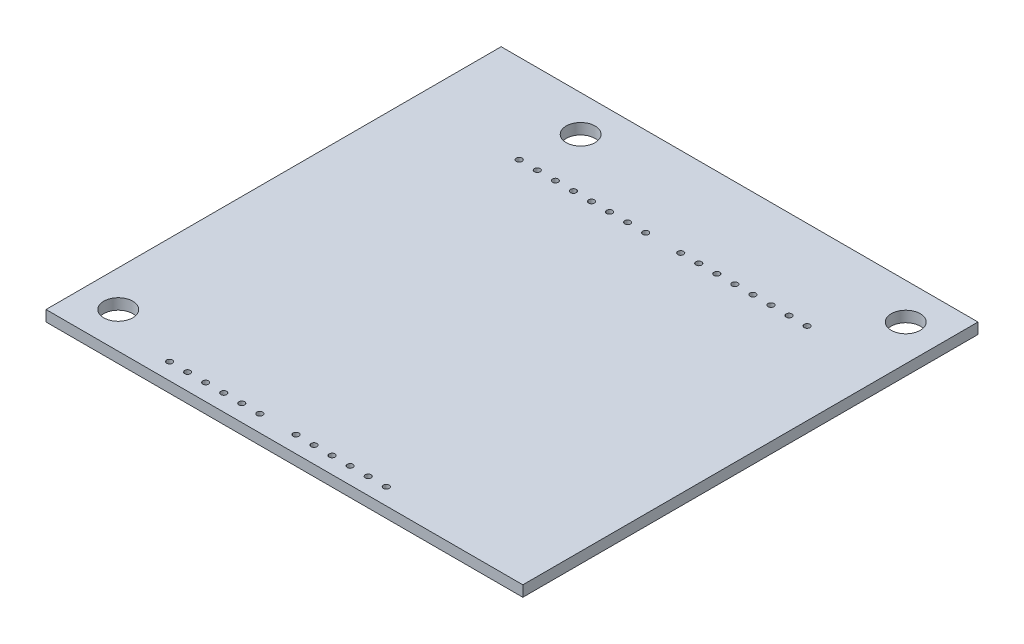
from build123d import *

# Parameters (mm, degrees)
SKETCH1_R           = 0.4
SKETCH1_R_2         = 2
BOSS_EXTRUDE1_DEPTH = 1.5


with BuildPart() as part:
    # Sketch1 → Boss-Extrude1 (new body)
    with BuildSketch(Plane(origin=(0, 0, 0), x_dir=(1, 0, 0), z_dir=(0, 1, 0))):
        Polygon((-28, -26.5), (28, -26.5), (28, 26.5), (28, 36.5), (-38, 36.5), (-38, -26.5), align=None)
        with Locations((-23.2, 24.2)):
            Circle(SKETCH1_R, mode=Mode.SUBTRACT)
        with Locations((-20.7, 24.2)):
            Circle(SKETCH1_R, mode=Mode.SUBTRACT)
        with Locations((-18.2, 24.2)):
            Circle(SKETCH1_R, mode=Mode.SUBTRACT)
        with Locations((-15.7, 24.2)):
            Circle(SKETCH1_R, mode=Mode.SUBTRACT)
        with Locations((-13.2, 24.2)):
            Circle(SKETCH1_R, mode=Mode.SUBTRACT)
        with Locations((-10.7, 24.2)):
            Circle(SKETCH1_R, mode=Mode.SUBTRACT)
        with Locations((-8.2, 24.2)):
            Circle(SKETCH1_R, mode=Mode.SUBTRACT)
        with Locations((-5.7, 24.2)):
            Circle(SKETCH1_R, mode=Mode.SUBTRACT)
        with Locations((-10.7, -24.2)):
            Circle(SKETCH1_R, mode=Mode.SUBTRACT)
        with Locations((-13.2, -24.2)):
            Circle(SKETCH1_R, mode=Mode.SUBTRACT)
        with Locations((-15.7, -24.2)):
            Circle(SKETCH1_R, mode=Mode.SUBTRACT)
        with Locations((-18.2, -24.2)):
            Circle(SKETCH1_R, mode=Mode.SUBTRACT)
        with Locations((-20.7, -24.2)):
            Circle(SKETCH1_R, mode=Mode.SUBTRACT)
        with Locations((-23.2, -24.2)):
            Circle(SKETCH1_R, mode=Mode.SUBTRACT)
        with Locations((6.8, -24.2)):
            Circle(SKETCH1_R, mode=Mode.SUBTRACT)
        with Locations((4.3, -24.2)):
            Circle(SKETCH1_R, mode=Mode.SUBTRACT)
        with Locations((1.8, -24.2)):
            Circle(SKETCH1_R, mode=Mode.SUBTRACT)
        with Locations((-0.7, -24.2)):
            Circle(SKETCH1_R, mode=Mode.SUBTRACT)
        with Locations((-3.2, -24.2)):
            Circle(SKETCH1_R, mode=Mode.SUBTRACT)
        with Locations((-5.7, -24.2)):
            Circle(SKETCH1_R, mode=Mode.SUBTRACT)
        with Locations((-0.85, 24.2)):
            Circle(SKETCH1_R, mode=Mode.SUBTRACT)
        with Locations((1.65, 24.2)):
            Circle(SKETCH1_R, mode=Mode.SUBTRACT)
        with Locations((4.15, 24.2)):
            Circle(SKETCH1_R, mode=Mode.SUBTRACT)
        with Locations((6.65, 24.2)):
            Circle(SKETCH1_R, mode=Mode.SUBTRACT)
        with Locations((9.15, 24.2)):
            Circle(SKETCH1_R, mode=Mode.SUBTRACT)
        with Locations((11.65, 24.2)):
            Circle(SKETCH1_R, mode=Mode.SUBTRACT)
        with Locations((14.15, 24.2)):
            Circle(SKETCH1_R, mode=Mode.SUBTRACT)
        with Locations((16.65, 24.2)):
            Circle(SKETCH1_R, mode=Mode.SUBTRACT)
        with Locations((-22, 31.5)):
            Circle(SKETCH1_R_2, mode=Mode.SUBTRACT)
        with Locations((23, 31.5)):
            Circle(SKETCH1_R_2, mode=Mode.SUBTRACT)
        with Locations((-33, -21.5)):
            Circle(SKETCH1_R_2, mode=Mode.SUBTRACT)
    extrude(amount=BOSS_EXTRUDE1_DEPTH)


solid = part.part
